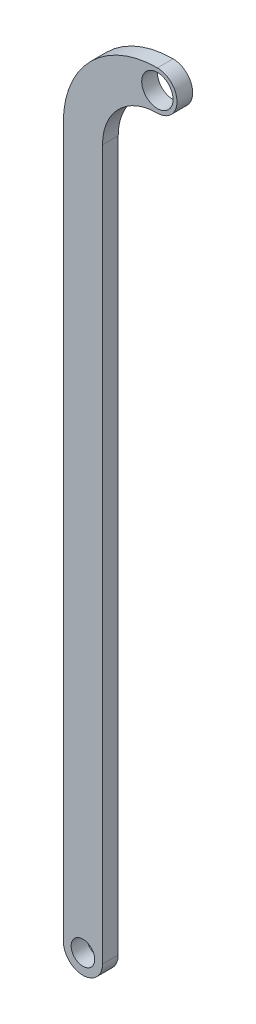
from build123d import *

# Parameters (mm, degrees)
SKETCH2_R           = 1
SKETCH2_R_2         = 0.75
BOSS_EXTRUDE1_DEPTH = 1


with BuildPart() as part:
    # Sketch2 → Boss-Extrude1 (new body)
    with BuildSketch(Plane.XY):
        with BuildLine():
            Line((-6, -4.75), (-6, -50))
            ThreePointArc((-6, -50), (-4.75, -51.25), (-3.5, -50))
            Line((-3.5, -50), (-3.5, -4.75))
            ThreePointArc((-3.5, -4.75), (-2.474873734, -2.275126266), (0, -1.25))
            ThreePointArc((0, -1.25), (1.25, 0), (0, 1.25))
            ThreePointArc((0, 1.25), (-4.242640687, -0.507359313), (-6, -4.75))
        make_face()
        Circle(SKETCH2_R, mode=Mode.SUBTRACT)
        with Locations((-4.75, -50)):
            Circle(SKETCH2_R_2, mode=Mode.SUBTRACT)
    extrude(amount=BOSS_EXTRUDE1_DEPTH)


solid = part.part
